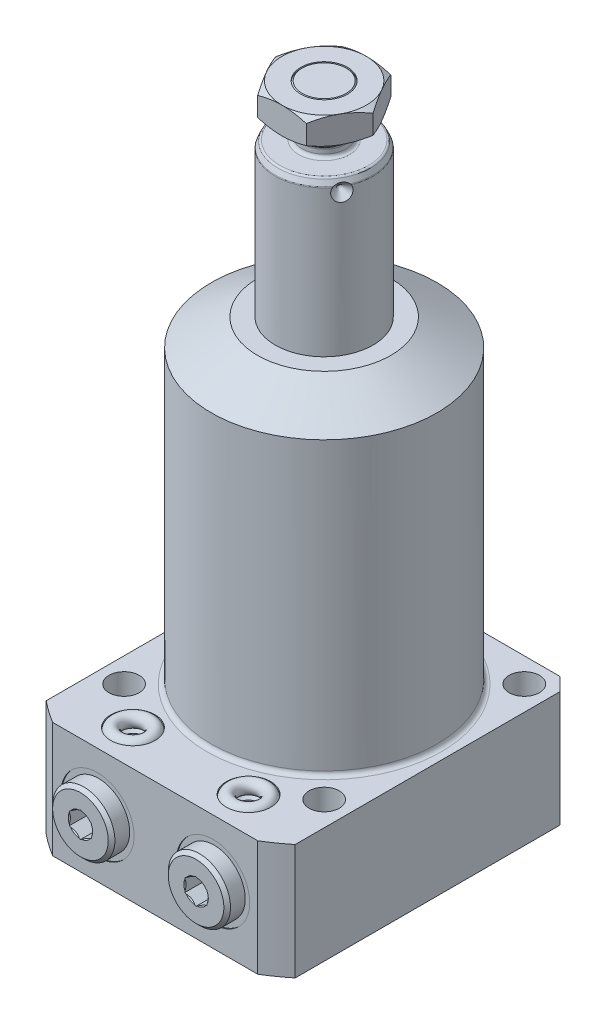
from build123d import *

# Parameters (mm, degrees)
FILLET2_R           = 0.75
FILLET3_R           = 0.5
SKETCH3_R           = 5.25
EXTRUDE3_DEPTH      = 6
CIRPATTERN1_COUNT   = 3
SKETCH7_OUTSIDE_W   = 129.056
SKETCH7_OUTSIDE_H   = 129.056
SKETCH7_OUTSIDE_W_2 = 56
SKETCH7_OUTSIDE_H_2 = 66
CUT_EXTRUDE5_DEPTH  = 27
SKETCH8_R           = 3.4
CUT_EXTRUDE6_DEPTH  = 27
CIRPATTERN2_COUNT   = 4
CHAMFER1_SIZE       = 3
FILLET5_R           = 1
CUT_EXTRUDE8_DEPTH  = 4.06
SKETCH16_R          = 1.5


with BuildPart() as part:
    # Sketch1 → Revolve2 (revolve)
    with BuildSketch(Plane.XY, mode=Mode.PRIVATE) as revolve2_sk:
        Polygon((11, 0), (11, 104.5), (10.300538513, 106), (5, 106), (5, 108), (5.935, 108.935), (5.935, 116.5), (4.935, 117.5), (0, 117.5), (0, 0), align=None)
    revolve(revolve2_sk.sketch.rotate(Axis((0, -3.075, 0), (0, 1, 0)), 90), axis=Axis((0, -3.075, 0), (0, 1, 0)))  # turned: the seam where the file's is

    # Fillet2
    fillet2_edges = [part.edges().sort_by_distance(p)[0] for p in [
        (0, 106, 5),
        (0, 108, 5),
    ]]
    fillet(fillet2_edges, radius=FILLET2_R)

    # Fillet3
    fillet3_edges = [part.edges().sort_by_distance(p)[0] for p in [
        (0, 104.5, 11),
        (0, 106, 10.300538513),
    ]]
    fillet(fillet3_edges, radius=FILLET3_R)

    # Sketch2 → Cut-Revolve1 (revolve, cut)
    with BuildSketch(Plane(origin=(0, 0, 0), x_dir=(0, 0, -1), z_dir=(1, 0, 0)), mode=Mode.PRIVATE) as cut_revolve1_sk:
        Polygon((9, 103.33), (11, 101.33), (11, 103.33), align=None)
    cut_revolve1 = revolve(cut_revolve1_sk.sketch.rotate(Axis((0, 103.33, -4.20155099), (0, 0, -1)), 90), axis=Axis((0, 103.33, -4.20155099), (0, 0, -1)), mode=Mode.SUBTRACT)  # turned: the seam where the file's is

    # Sketch3 → Extrude3 (add)
    with BuildSketch(Plane(origin=(0, 117.5, 0), x_dir=(1, 0, 0), z_dir=(0, 1, 0))):
        Polygon((10.969655115, 0), (5.484827557, 9.5), (-5.484827557, 9.5), (-10.969655115, 0), (-5.484827557, -9.5), (5.484827557, -9.5), align=None)
        with Locations(Location((0, 0, 0), (0, 0, 270))):  # turned: the seam where the file's is
            Circle(SKETCH3_R, mode=Mode.SUBTRACT)
    extrude(amount=-EXTRUDE3_DEPTH)

    # CirPattern1: Cut-Revolve1 ×3 about axis
    cirpattern1_axis = Axis((0, -3.075, 0), (0, -1, 0))
    for i in range(1, CIRPATTERN1_COUNT):
        add(cut_revolve1.rotate(cirpattern1_axis, i * 360 / CIRPATTERN1_COUNT), mode=Mode.SUBTRACT)

    # Sketch4 → Cut-Revolve3 (revolve, cut)
    with BuildSketch(Plane(origin=(0, 0, 0), x_dir=(0, 0, -1), z_dir=(1, 0, 0))):
        Polygon((9.5, 117.5), (12.5, 117.5), (12.5, 115.767949192), align=None)
        Polygon((12.5, 113.232050808), (9.5, 111.5), (12.5, 111.5), align=None)
    revolve(axis=Axis((0, -3.075, 0), (0, -1, 0)), mode=Mode.SUBTRACT)

    # Sketch6 → Revolve3 (revolve)
    with BuildSketch(Plane.XY, mode=Mode.PRIVATE) as revolve3_sk:
        Polygon((0, 71.5), (15, 71.5), (25.385, 65.504217454), (25.385, 0), (44.45, 0), (44.45, -26), (0, -26), align=None)
    revolve(revolve3_sk.sketch.rotate(Axis((0, 0, 0), (0, 1, 0)), 90), axis=Axis((0, 0, 0), (0, 1, 0)))  # turned: the seam where the file's is

    # Sketch7 outside → Cut-Extrude5 (cut, through all)
    with BuildSketch(Plane(origin=(0, 0, 0), x_dir=(-1, 0, 0), z_dir=(0, 1, 0))):
        Rectangle(SKETCH7_OUTSIDE_W, SKETCH7_OUTSIDE_H)
        with Locations((0, 5)):
            Rectangle(SKETCH7_OUTSIDE_W_2, SKETCH7_OUTSIDE_H_2, mode=Mode.SUBTRACT)
    extrude(amount=-CUT_EXTRUDE5_DEPTH, mode=Mode.SUBTRACT)

    # Sketch8 → Cut-Extrude6 (cut, through all)
    with BuildSketch(Plane(origin=(0, 0, 0), x_dir=(-1, 0, 0), z_dir=(0, 1, 0))):
        with Locations(Location((-22.5, 22.5, 0), (0, 0, 90))):  # turned: the seam where the file's is
            Circle(SKETCH8_R)
    cut_extrude6 = extrude(amount=-CUT_EXTRUDE6_DEPTH, mode=Mode.SUBTRACT)

    # CirPattern2: Cut-Extrude6 ×4 about axis
    cirpattern2_axis = Axis((0, 0, 0), (0, 1, 0))
    for i in range(1, CIRPATTERN2_COUNT):
        add(cut_extrude6.rotate(cirpattern2_axis, i * 360 / CIRPATTERN2_COUNT), mode=Mode.SUBTRACT)

    # Chamfer1
    chamfer1_edges = [part.edges().sort_by_distance(p)[0] for p in [
        (-28, -13, -28),
        (28, -13, -28),
    ]]
    chamfer(chamfer1_edges, length=CHAMFER1_SIZE)

    # Fillet5
    fillet5_edges = [part.edges().sort_by_distance(p)[0] for p in [
        (0, 0, 25.385),
    ]]
    fillet(fillet5_edges, radius=FILLET5_R)

    # Sketch11 → Cut-Revolve5 (revolve, cut)
    with BuildSketch(Plane(origin=(0, -13, 0), x_dir=(-1, 0, 0), z_dir=(0, 1, 0))):
        Polygon((-21.25, 38), (-21.25, 37.75), (-18, 37.75), (-17.42, 37.17), (-17.42, 22.59), (-13, 22.59), (-13, 38), align=None)
    cut_revolve5 = revolve(axis=Axis((13, -13, 42.971570338), (0, 0, -1)), mode=Mode.SUBTRACT)

    # Sketch13 → Cut-Revolve6 (revolve, cut)
    with BuildSketch(Plane.XY.offset(30), mode=Mode.PRIVATE) as cut_revolve6_sk:
        Polygon((-15.5, -14), (-15.5, -23.125), (-16.125, -23.75), (-18, -23.75), (-18, -26), (-13, -26), (-13, -14), align=None)
    cut_revolve6 = revolve(cut_revolve6_sk.sketch.rotate(Axis((-13, -28.848676706, 30), (0, 1, 0)), 180), axis=Axis((-13, -28.848676706, 30), (0, 1, 0)), mode=Mode.SUBTRACT)  # turned: the seam where the file's is

    # Mirror4: Cut-Revolve6 across plane
    add(cut_revolve6.mirror(Plane.ZX.offset(-13)), mode=Mode.SUBTRACT)

    # Sketch14 → Revolve6 (revolve)
    with BuildSketch(Plane(origin=(0, -13, 0), x_dir=(-1, 0, 0), z_dir=(0, 1, 0)), mode=Mode.PRIVATE) as revolve6_sk:
        Polygon((-15.75, 41.81), (-19.25, 41.81), (-20, 41.06), (-20, 37.75), (-17.125, 37.75), (-17.125, 35.30784845), (-13, 35.30784845), (-13, 35.30884845), (-15.5, 36.810999998), (-15.5, 41.56), align=None)
    revolve6 = revolve(revolve6_sk.sketch.rotate(Axis((13, -13, 32.588064048), (0, 0, 1)), 180), axis=Axis((13, -13, 32.588064048), (0, 0, 1)))  # turned: the seam where the file's is

    # Sketch15 → Cut-Extrude8 (cut)
    with BuildSketch(Plane.XY.offset(41.81)):
        Polygon((15.5, -14.443375673), (15.5, -11.556624327), (13, -10.113248654), (10.5, -11.556624327), (10.5, -14.443375673), (13, -15.886751346), align=None)
    cut_extrude8 = extrude(amount=-CUT_EXTRUDE8_DEPTH, mode=Mode.SUBTRACT)

    # Mirror1: Cut-Revolve5, Cut-Revolve6, Revolve6, Cut-Extrude8 across plane
    add(cut_revolve5.mirror(Plane(origin=(0, 0, 0), x_dir=(0, 0, 1), z_dir=(1, 0, 0))), mode=Mode.SUBTRACT)
    add(cut_revolve6.mirror(Plane(origin=(0, 0, 0), x_dir=(0, 0, 1), z_dir=(1, 0, 0))), mode=Mode.SUBTRACT)
    add(revolve6.mirror(Plane(origin=(0, 0, 0), x_dir=(0, 0, 1), z_dir=(1, 0, 0))))
    add(cut_extrude8.mirror(Plane(origin=(0, 0, 0), x_dir=(0, 0, 1), z_dir=(1, 0, 0))), mode=Mode.SUBTRACT)

    # Mirror1 copy 1 sketch → Mirror1 copy 1 (revolve, cut)
    with BuildSketch(Plane(origin=(0, -26, 30), x_dir=(-1, 0, 0), z_dir=(0, 0, 1))):
        Polygon((-15.5, -14), (-15.5, -23.125), (-16.125, -23.75), (-18, -23.75), (-18, -26), (-13, -26), (-13, -14), align=None)
    revolve(axis=Axis((13, 2.848676706, 30), (0, -1, 0)), mode=Mode.SUBTRACT)


with BuildPart() as body_2:
    # Sketch16 → Revolve7 (revolve)
    with BuildSketch(Plane.XY.offset(30), mode=Mode.PRIVATE) as revolve7_sk:
        with Locations((-16.5, -0.75)):
            Circle(SKETCH16_R)
    revolve(revolve7_sk.sketch.rotate(Axis((-13, 9.321927472, 30), (0, -1, 0)), 180), axis=Axis((-13, 9.321927472, 30), (0, -1, 0)))  # turned: the seam where the file's is


with BuildPart() as body_3:
    # Mirror3: mirrored copy
    add(body_2.part.mirror(Plane(origin=(0, 0, 0), x_dir=(0, 0, 1), z_dir=(1, 0, 0))))


with BuildPart() as body_4:
    # Mirror5: mirrored copy
    add(body_2.part.mirror(Plane.ZX.offset(-13)))


with BuildPart() as body_5:
    # Mirror5 2: mirrored copy
    add(body_3.part.mirror(Plane.ZX.offset(-13)))


solid = Compound([part.part, body_2.part, body_3.part, body_4.part, body_5.part])
